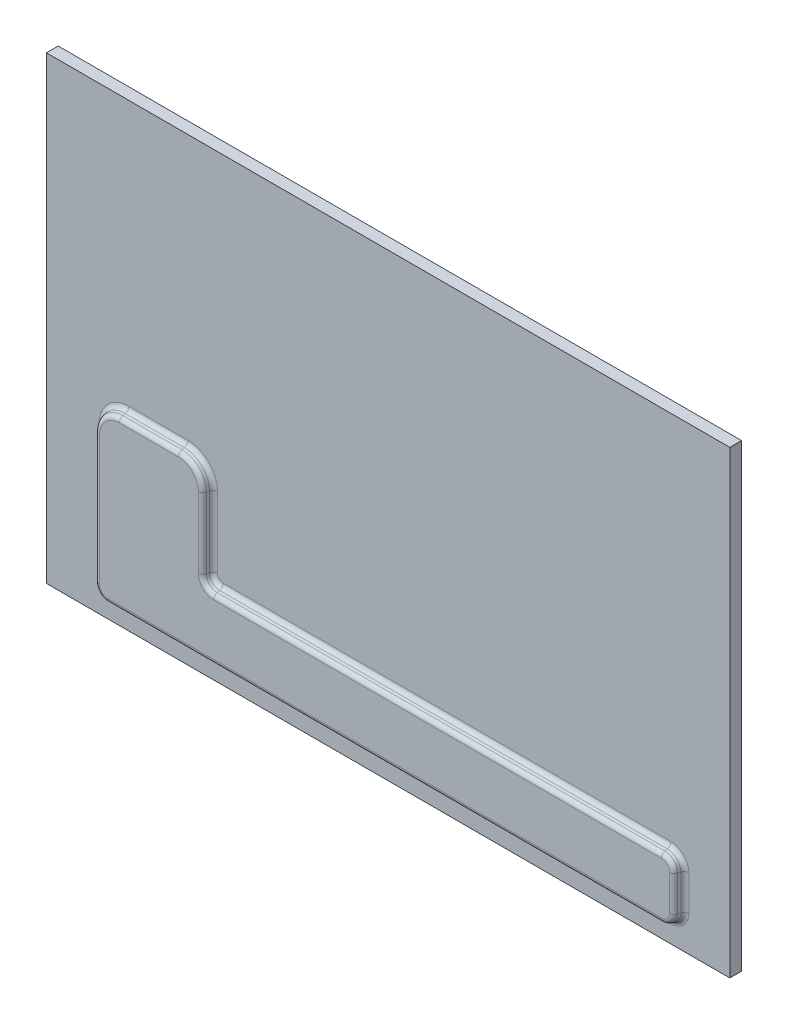
from build123d import *

# Parameters (mm, degrees)
SKETCH_1_W      = 290
SKETCH_1_H      = 195
EXTRUDE_1_DEPTH = 5
EXTRUDE_2_DEPTH = 4
FILLET_1_R      = 5
FILLET_2_R      = 10
DRAFT_2_ANGLE   = 15
FILLET_3_R      = 2


with BuildPart() as part:
    # 草图1 → 凸台-拉伸1 (new body)
    with BuildSketch(Plane.XY):
        Rectangle(SKETCH_1_W, SKETCH_1_H)
    extrude(amount=EXTRUDE_1_DEPTH)

    # 草图2 → 凸台-拉伸2 (add)
    with BuildSketch(Plane.XY.offset(5)):
        Polygon((-75, -17.5), (-120, -17.5), (-120, -87.5), (125, -87.5), (125, -62.5), (-75, -62.5), align=None)
    extrude(amount=EXTRUDE_2_DEPTH)

    # 圆角1
    fillet_1_edges = [part.edges().sort_by_distance(p)[0] for p in [
        (-75, -62.5, 7),
        (-120, -87.5, 7),
        (125, -87.5, 7),
        (125, -62.5, 7),
    ]]
    fillet(fillet_1_edges, radius=FILLET_1_R)

    # 圆角2
    fillet_2_edges = [part.edges().sort_by_distance(p)[0] for p in [
        (-75, -17.5, 7),
        (-120, -17.5, 7),
    ]]
    fillet(fillet_2_edges, radius=FILLET_2_R)

    # 拔模2
    draft_2_faces = [part.faces().sort_by_distance(p)[0] for p in [
        (-73.535533906, -61.035533906, 7),
        (123.535533906, -63.964466094, 7),
        (123.535533906, -86.035533906, 7),
        (125, -75, 7),
        (25, -62.5, 7),
        (-75, -42.5, 7),
        (-77.928932188, -20.428932188, 7),
        (-97.5, -17.5, 7),
        (-117.071067812, -20.428932188, 7),
        (-120, -55, 7),
        (-118.535533906, -86.035533906, 7),
        (2.5, -87.5, 7),
    ]]
    draft(draft_2_faces, Plane.XY.offset(9), DRAFT_2_ANGLE)

    # 圆角3
    fillet_3_edges = [part.edges().sort_by_distance(p)[0] for p in [
        (25, -61.42820323, 5),
        (25, -62.5, 9),
        (126.07179677, -75, 5),
        (125, -75, 9),
        (-75, -42.5, 9),
        (2.5, -87.5, 9),
        (-118.535533906, -86.035533906, 9),
        (123.535533906, -86.035533906, 9),
        (123.535533906, -63.964466094, 9),
        (-73.92820323, -42.5, 5),
        (2.5, -88.57179677, 5),
        (-72.777659142, -60.277659142, 5),
        (124.29340867, -63.20659133, 5),
        (-73.535533906, -61.035533906, 9),
        (124.29340867, -86.79340867, 5),
        (-119.29340867, -86.79340867, 5),
        (-97.5, -16.42820323, 5),
        (-97.5, -17.5, 9),
        (-120, -55, 9),
        (-117.071067812, -20.428932188, 9),
        (-77.928932188, -20.428932188, 9),
        (-121.07179677, -55, 5),
        (-77.171057424, -19.671057424, 5),
        (-117.828942576, -19.671057424, 5),
    ]]
    fillet(fillet_3_edges, radius=FILLET_3_R)


solid = part.part
